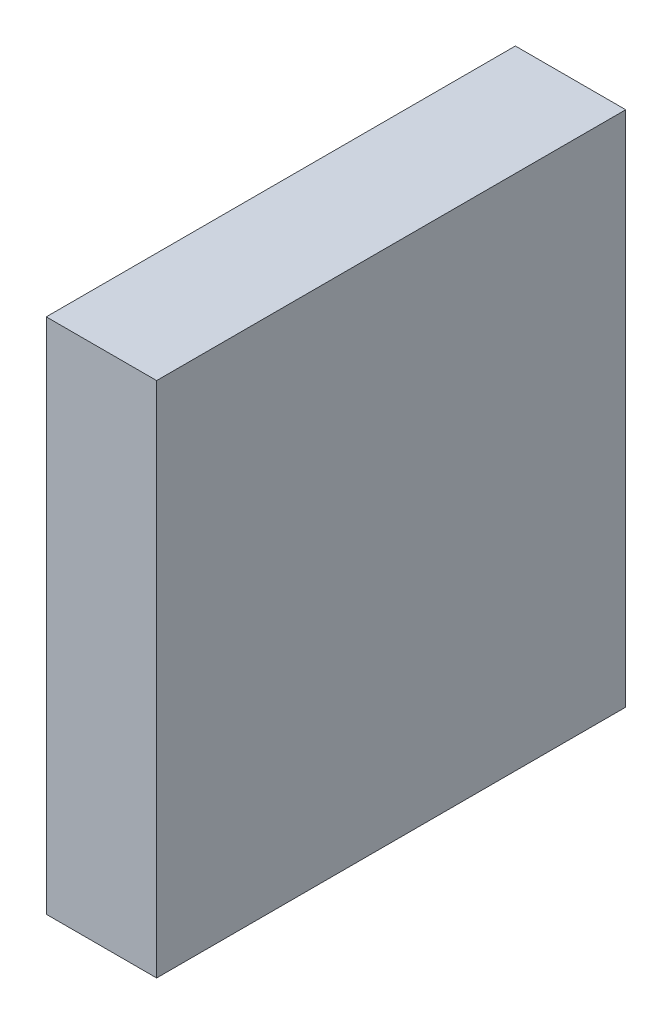
from build123d import *

# Parameters (mm, degrees)
CROQUIS1_W              = 16
CROQUIS1_H              = 75
SALIENTE_EXTRUIR1_DEPTH = 68


with BuildPart() as part:
    # Croquis1 → Saliente-Extruir1 (new body)
    with BuildSketch(Plane.XY):
        Rectangle(CROQUIS1_W, CROQUIS1_H)
    extrude(amount=SALIENTE_EXTRUIR1_DEPTH)


solid = part.part
